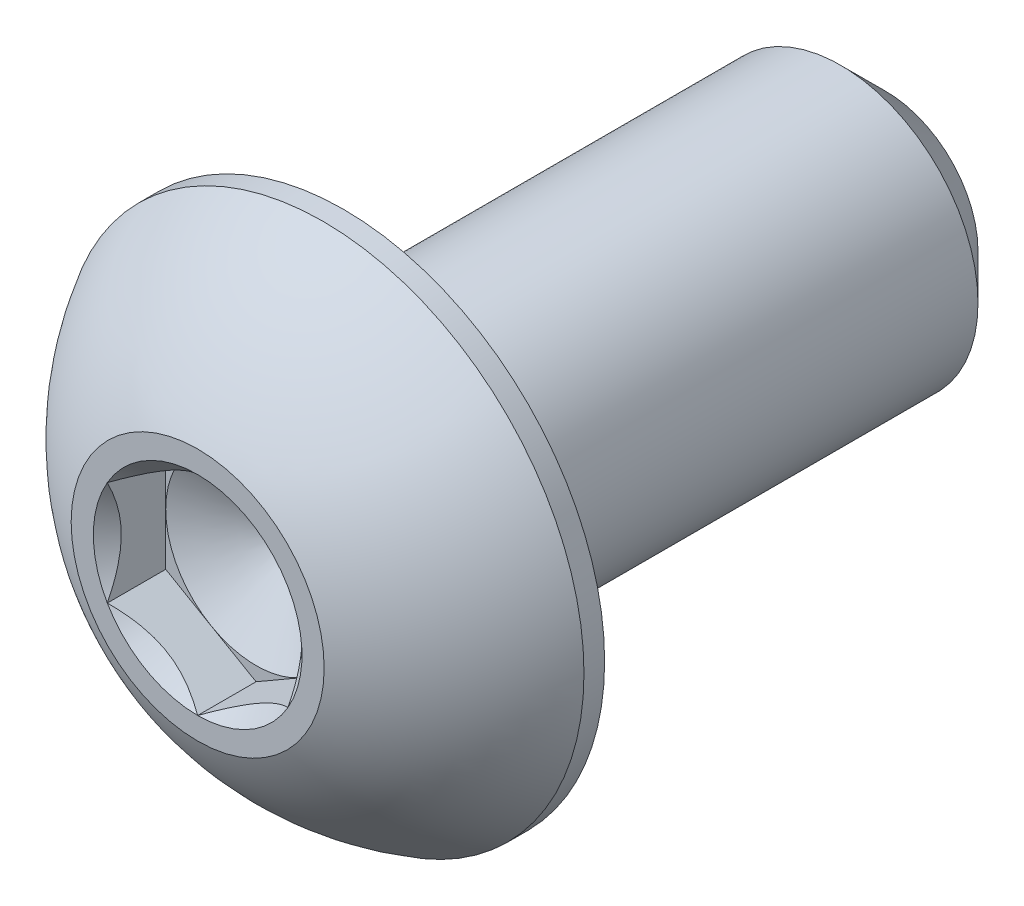
from build123d import *

# Parameters (mm, degrees)
CUT_EXTRUDE1_START = 5.01904
CUT_EXTRUDE1_DEPTH = 2.02616
SKETCH4_R          = 1.833087105
CUT_EXTRUDE2_DEPTH = 1.02616
CUT_EXTRUDE2_DRAFT = -45


with BuildPart() as part:
    # Sketch2 → Revolve1 (revolve)
    with BuildSketch(Plane(origin=(0, 0, 0), x_dir=(0, 0, -1), z_dir=(1, 0, 0))):
        with BuildLine():
            Line((-6.0452, 1.5875), (-6.0452, 2.2225))
            ThreePointArc((-6.0452, 2.2225), (-5.130252118, 3.57733025), (-3.842657143, 4.5847))
            Line((-3.842657143, 4.5847), (-3.4798, 4.5847))
            Line((-3.4798, 4.5847), (-3.4798, 2.413))
            Line((-3.4798, 2.413), (5.25145, 2.413))
            Line((5.25145, 2.413), (6.0452, 1.61925))
            Line((6.0452, 1.61925), (6.0452, 0))
            Line((6.0452, 0), (-4.102496448, 0))
            Line((-4.102496448, 0), (-5.01904, 1.5875))
            Line((-5.01904, 1.5875), (-6.0452, 1.5875))
        make_face()
    revolve(axis=Axis((0, 0, 6.0452), (0, 0, -1)))

    # Sketch3 → Cut-Extrude1 (cut, through all)
    with BuildSketch(Plane.XY.offset(CUT_EXTRUDE1_START)):
        Polygon((0, 1.833087105), (-1.5875, 0.916543552), (-1.5875, -0.916543552), (0, -1.833087105), (1.5875, -0.916543552), (1.5875, 0.916543552), align=None)
    extrude(amount=CUT_EXTRUDE1_DEPTH, mode=Mode.SUBTRACT)


with BuildPart() as cut_extrude2_tool:
    # Sketch4 → Cut-Extrude2 (with draft: the straight prism first)
    with BuildSketch(Plane.XY.offset(6.0452)):
        Circle(SKETCH4_R)
    extrude(amount=-CUT_EXTRUDE2_DEPTH)
    # Cut-Extrude2: the draft: its side faces are tilted about the plane it starts from
    cut_extrude2_sides = [cut_extrude2_tool.faces().sort_by_distance(p)[0] for p in [
        (-1.833087105, 0, 5.53212),
    ]]
    draft(cut_extrude2_sides, Plane.XY.offset(6.0452), CUT_EXTRUDE2_DRAFT)


with BuildPart() as part_1:
    add(part.part)

    # Cut-Extrude2: cut by cut_extrude2_tool
    add(cut_extrude2_tool.part, mode=Mode.SUBTRACT)


solid = part_1.part
